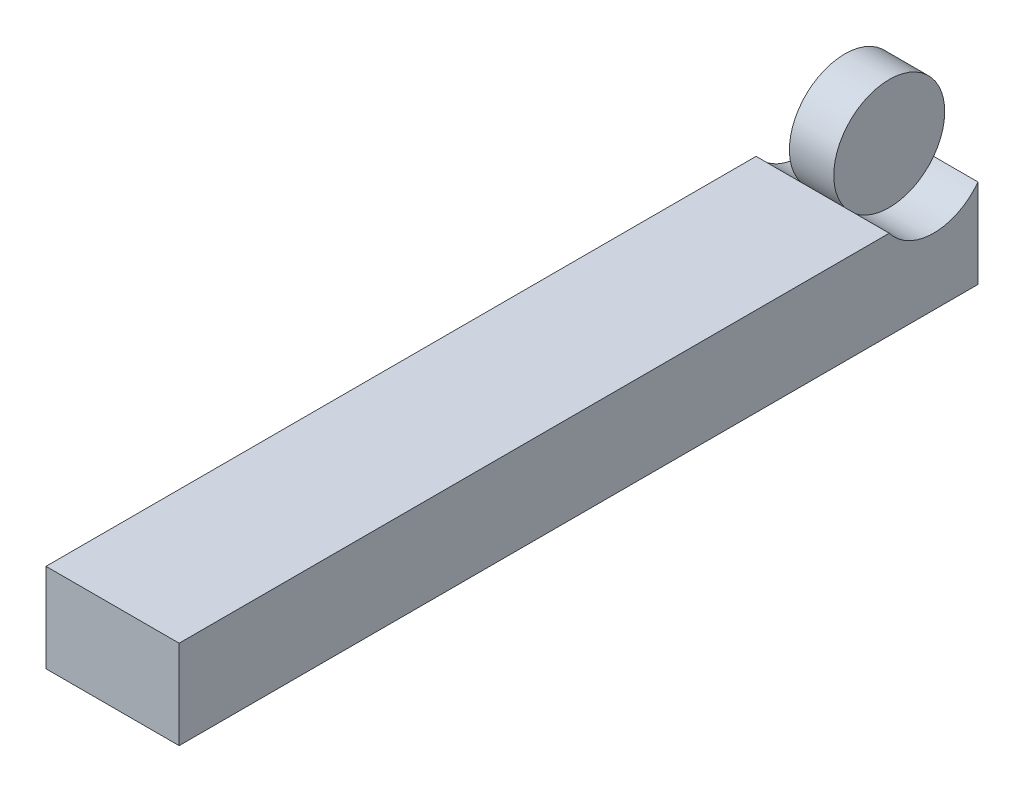
from build123d import *

# Parameters (mm, degrees)
SKETCH2_W           = 180
SKETCH2_H           = 20
BOSS_EXTRUDE1_DEPTH = 30
SKETCH3_R           = 12.5
CUT_EXTRUDE2_DEPTH  = 31
SKETCH5_R           = 12.5
BOSS_EXTRUDE4_DEPTH = 5


with BuildPart() as part:
    # Sketch2 → Boss-Extrude1 (new body)
    with BuildSketch(Plane(origin=(0, 0, 0), x_dir=(0, 0, -1), z_dir=(1, 0, 0))):
        with Locations((90, 10)):
            Rectangle(SKETCH2_W, SKETCH2_H)
    extrude(amount=-BOSS_EXTRUDE1_DEPTH)

    # Sketch3 → Cut-Extrude2 (cut, through all)
    with BuildSketch(Plane(origin=(0, 0, 0), x_dir=(0, 0, -1), z_dir=(1, 0, 0))):
        with Locations((170, 27.5)):
            Circle(SKETCH3_R)
    extrude(amount=-CUT_EXTRUDE2_DEPTH, mode=Mode.SUBTRACT)

    # Sketch5 → Boss-Extrude4 (add, symmetric)
    with BuildSketch(Plane(origin=(-15, 0, 0), x_dir=(0, 0, -1), z_dir=(1, 0, 0))):
        with Locations((170, 27.5)):
            Circle(SKETCH5_R)
    extrude(amount=BOSS_EXTRUDE4_DEPTH, both=True)


solid = part.part
